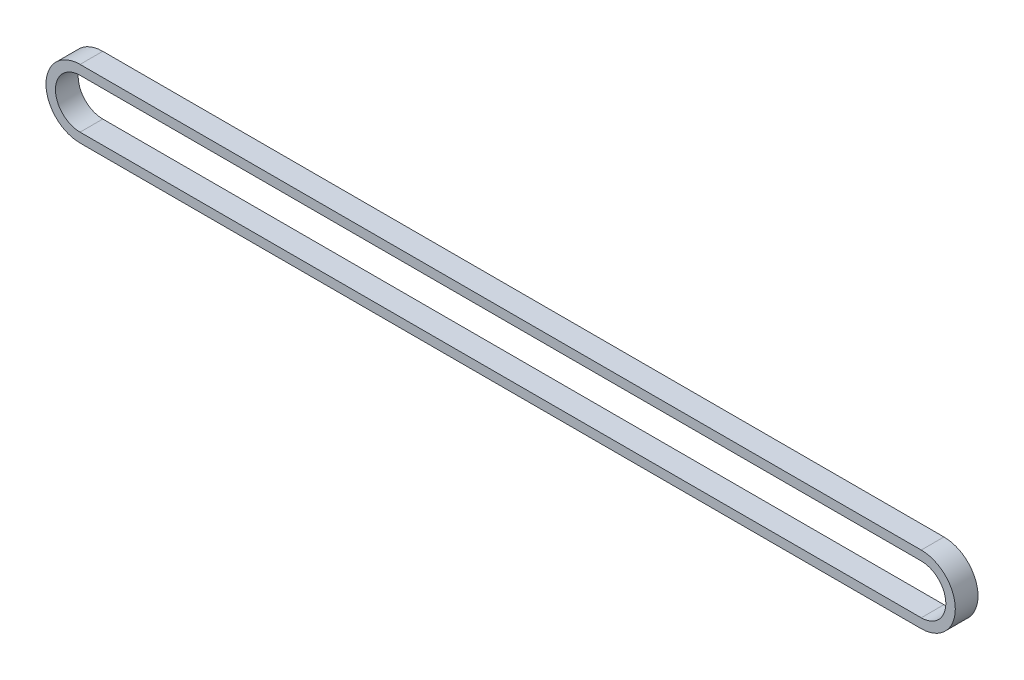
from build123d import *

# Parameters (mm, degrees)
BOSS_EXTRUDE1_DEPTH = 6


with BuildPart() as part:
    # Sketch2 → Boss-Extrude1 (new body)
    with BuildSketch(Plane.XY):
        with BuildLine():
            Line((-111.125, 9), (111.125, 9))
            ThreePointArc((111.125, 9), (120.125, 0), (111.125, -9))
            Line((111.125, -9), (-111.125, -9))
            ThreePointArc((-111.125, -9), (-120.125, 0), (-111.125, 9))
        make_face()
        with BuildLine():
            Line((-111.125, 6.5), (111.125, 6.5))
            ThreePointArc((111.125, 6.5), (117.625, 0), (111.125, -6.5))
            Line((111.125, -6.5), (-111.125, -6.5))
            ThreePointArc((-111.125, -6.5), (-117.625, 0), (-111.125, 6.5))
        make_face(mode=Mode.SUBTRACT)
    extrude(amount=BOSS_EXTRUDE1_DEPTH)


solid = part.part
